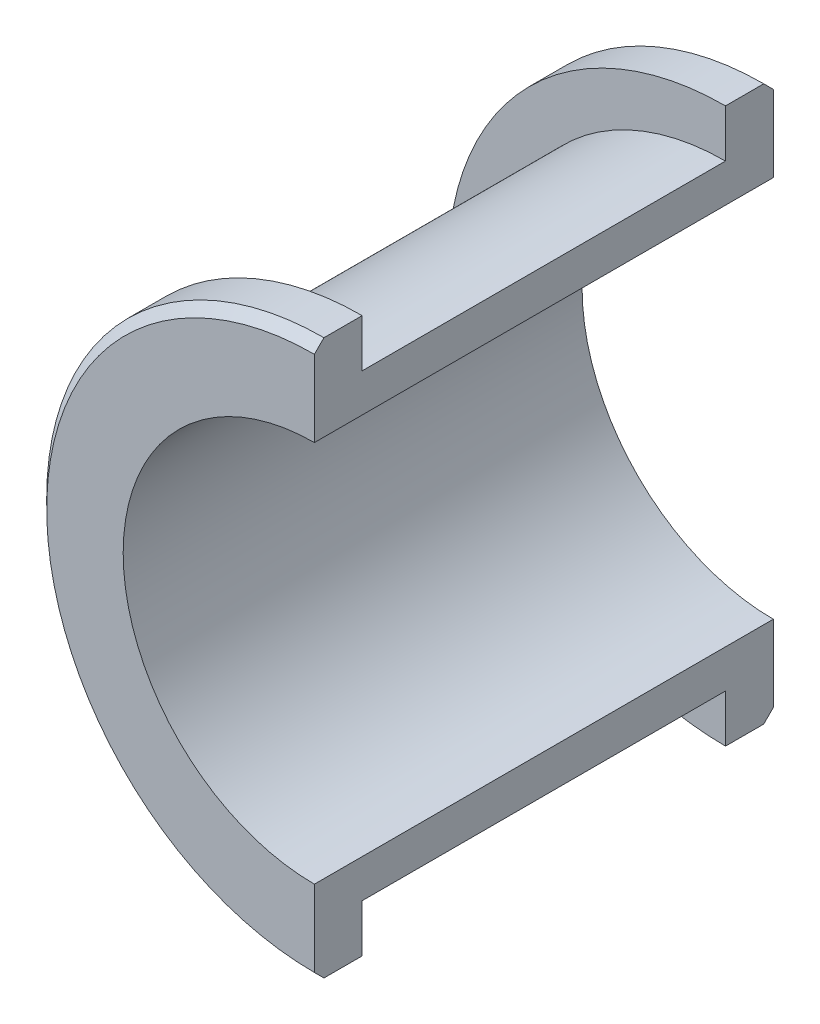
from build123d import *

# Parameters (mm, degrees)
SKETCH_1_R          = 24
SKETCH_1_R_2        = 20
EXTRUDE_1_DEPTH     = 24
SKETCH_2_R          = 29
SKETCH_2_R_2        = 24
EXTRUDE_2_DEPTH     = 5
SKETCH_3_W          = 29
SKETCH_3_H          = 58
CUT_EXTRUDE_1_DEPTH = 49
CHAMFER_1_SIZE      = 1


with BuildPart() as part:
    # Эскиз1 → Бобышка-Вытянуть1 (new body)
    with BuildSketch(Plane.XY):
        Circle(SKETCH_1_R)
        Circle(SKETCH_1_R_2, mode=Mode.SUBTRACT)
    extrude(amount=EXTRUDE_1_DEPTH)

    # Эскиз2 → Бобышка-Вытянуть2 (add)
    with BuildSketch(Plane.XY.offset(24)):
        Circle(SKETCH_2_R)
        Circle(SKETCH_2_R_2, mode=Mode.SUBTRACT)
    extrude(amount=-EXTRUDE_2_DEPTH)

    # Зеркальное отражение1: part across plane


with BuildPart() as part_1:
    add(part.part)
    add(part.part.mirror(Plane.XY))

    # Эскиз3 → Вырез-Вытянуть1 (cut, through all)
    with BuildSketch(Plane.XY.offset(24)):
        with Locations((14.5, 0)):
            Rectangle(SKETCH_3_W, SKETCH_3_H)
    extrude(amount=-CUT_EXTRUDE_1_DEPTH, mode=Mode.SUBTRACT)

    # Фаска1
    chamfer_1_edges = [part_1.edges().sort_by_distance(p)[0] for p in [
        (-29, 0, -24),
        (-29, 0, 24),
    ]]
    chamfer(chamfer_1_edges, length=CHAMFER_1_SIZE)


solid = part_1.part
